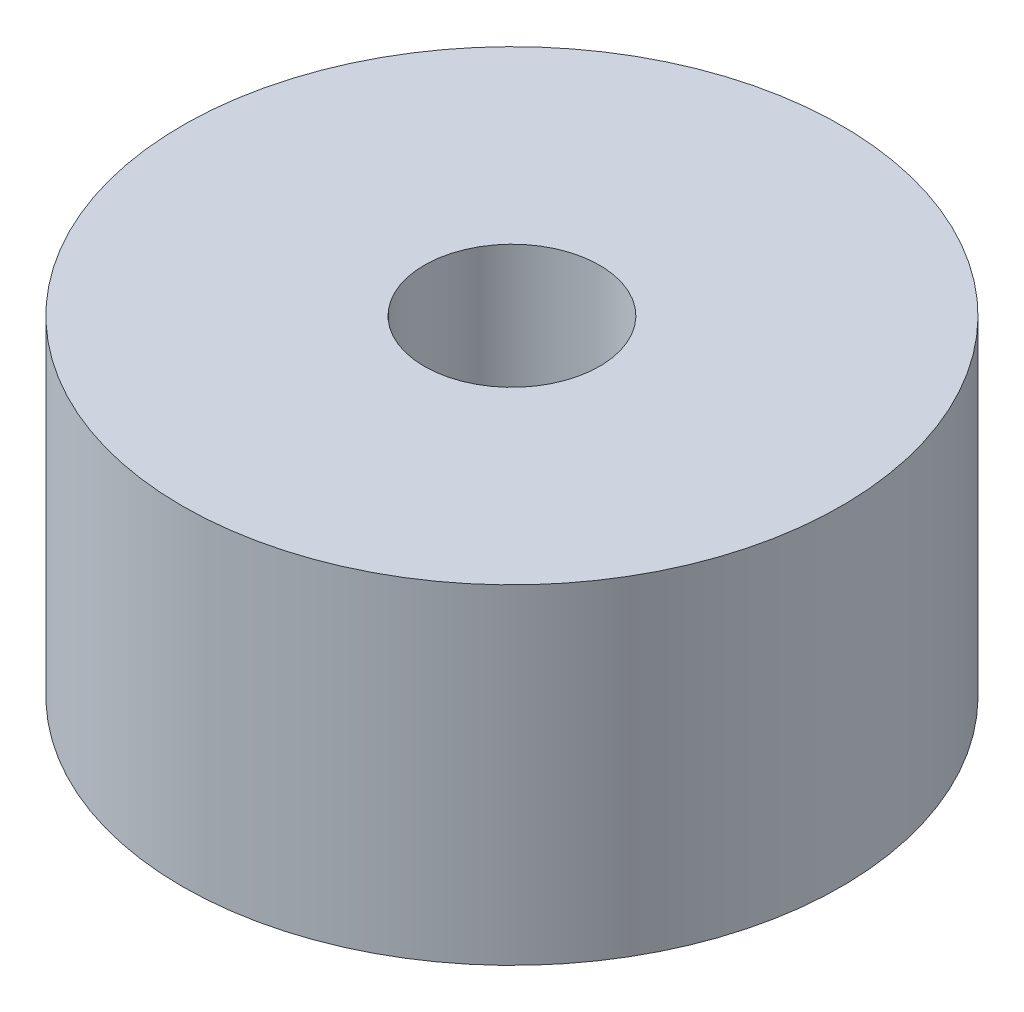
from build123d import *

# Parameters (mm, degrees)
SKETCH1_R           = 6.35
SKETCH1_R_2         = 1.6891
BOSS_EXTRUDE1_DEPTH = 6.35


with BuildPart() as part:
    # Sketch1 → Boss-Extrude1 (new body)
    with BuildSketch(Plane(origin=(0, 0, 0), x_dir=(1, 0, 0), z_dir=(0, 1, 0))):
        Circle(SKETCH1_R)
        Circle(SKETCH1_R_2, mode=Mode.SUBTRACT)
    extrude(amount=BOSS_EXTRUDE1_DEPTH)


solid = part.part
